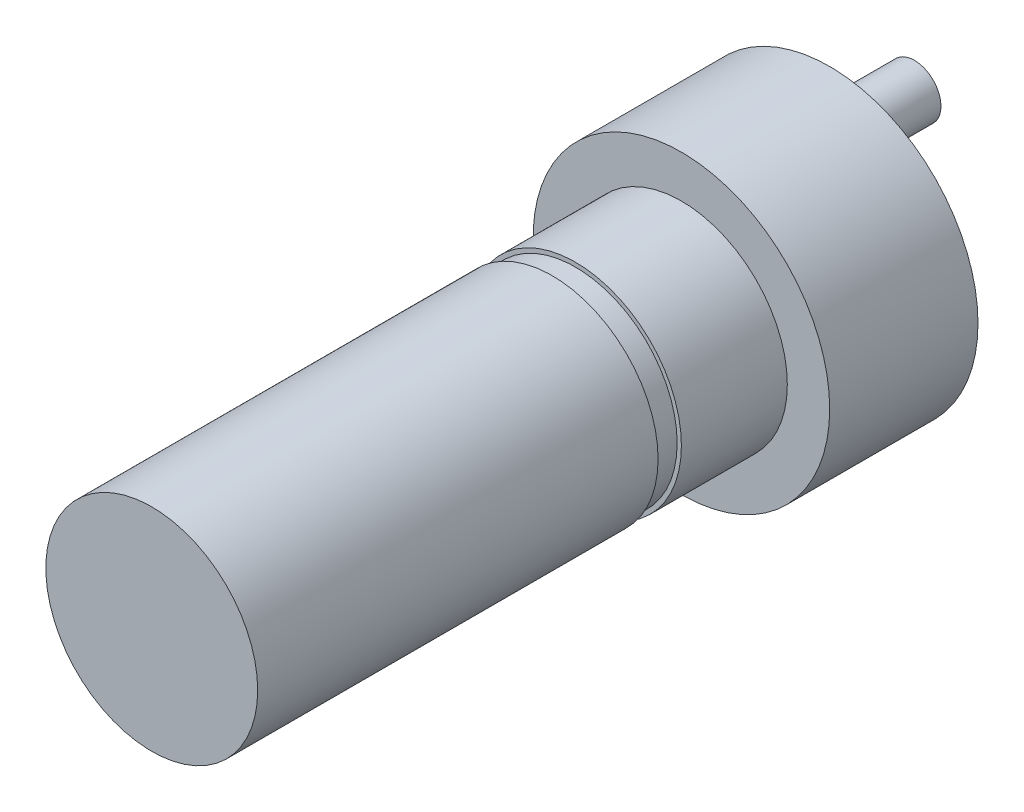
from build123d import *

# Parameters (mm, degrees)
SKETCH1_R           = 7
BOSS_EXTRUDE1_DEPTH = 7
SKETCH2_R           = 5
BOSS_EXTRUDE2_DEPTH = 25
SKETCH3_R           = 6
SKETCH3_R_2         = 4.8
CUT_EXTRUDE1_DEPTH  = 1.1
SKETCH4_R           = 1.25
BOSS_EXTRUDE3_DEPTH = 4


with BuildPart() as part:
    # Sketch1 → Boss-Extrude1 (new body)
    with BuildSketch(Plane.XY):
        Circle(SKETCH1_R)
    extrude(amount=-BOSS_EXTRUDE1_DEPTH)

    # Sketch2 → Boss-Extrude2 (add)
    with BuildSketch(Plane.XY):
        Circle(SKETCH2_R)
    extrude(amount=BOSS_EXTRUDE2_DEPTH)

    # Sketch3 → Cut-Extrude1 (cut)
    with BuildSketch(Plane.XY.offset(5)):
        Circle(SKETCH3_R)
        Circle(SKETCH3_R_2, mode=Mode.SUBTRACT)
    extrude(amount=CUT_EXTRUDE1_DEPTH, mode=Mode.SUBTRACT)

    # Sketch4 → Boss-Extrude3 (add)
    with BuildSketch(Plane(origin=(0, 0, -7), x_dir=(-1, 0, 0), z_dir=(0, 0, -1))):
        with Locations((0, 4)):
            Circle(SKETCH4_R)
    extrude(amount=BOSS_EXTRUDE3_DEPTH)


solid = part.part
